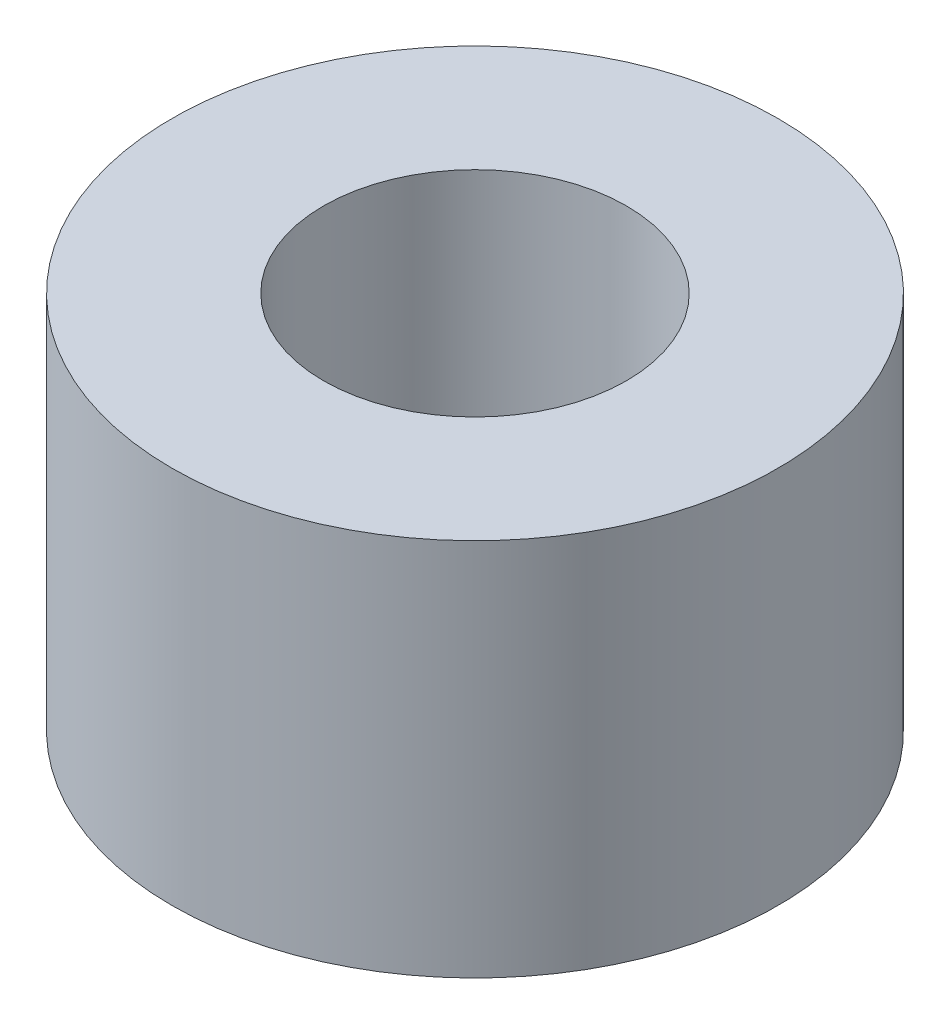
from build123d import *

# Parameters (mm, degrees)
SKETCH_1_R      = 4
SKETCH_1_R_2    = 2
EXTRUDE_1_DEPTH = 5


with BuildPart() as part:
    # 草图1 → 凸台-拉伸1 (new body)
    with BuildSketch(Plane(origin=(0, 0, 0), x_dir=(1, 0, 0), z_dir=(0, 1, 0))):
        Circle(SKETCH_1_R)
        Circle(SKETCH_1_R_2, mode=Mode.SUBTRACT)
    extrude(amount=EXTRUDE_1_DEPTH)


solid = part.part
